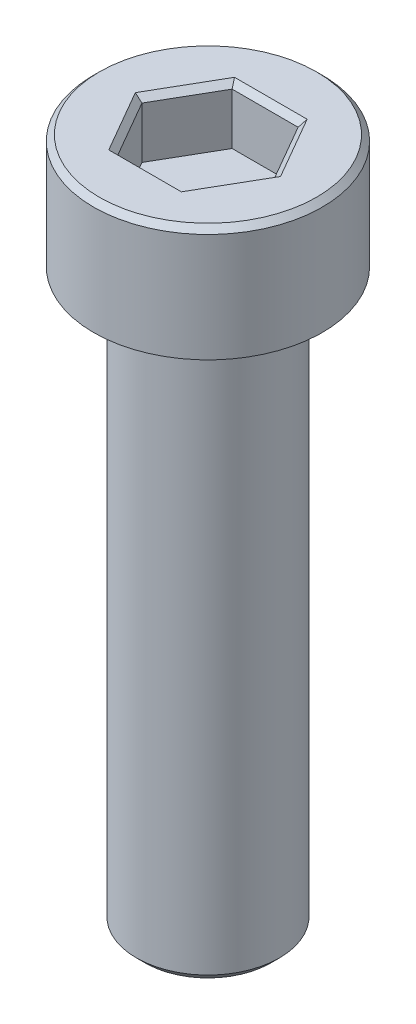
from build123d import *

# Parameters (mm, degrees)
SKETCH_1_R          = 4
EXTRUDE_1_DEPTH     = 4
SKETCH_2_R          = 2.5
EXTRUDE_2_DEPTH     = 20
CUT_EXTRUDE_1_DEPTH = 2
CHAMFER_1_SIZE      = 0.2
CHAMFER_2_SIZE      = 0.3


with BuildPart() as part:
    # 草图1 → 凸台-拉伸1 (new body)
    with BuildSketch(Plane(origin=(0, 0, 0), x_dir=(1, 0, 0), z_dir=(0, 1, 0))):
        Circle(SKETCH_1_R)
    extrude(amount=EXTRUDE_1_DEPTH)

    # 草图2 → 凸台-拉伸2 (add)
    with BuildSketch(Plane.XZ):
        Circle(SKETCH_2_R)
    extrude(amount=EXTRUDE_2_DEPTH)

    # 草图11 → 切除-拉伸1 (cut)
    with BuildSketch(Plane(origin=(0, 4, 0), x_dir=(1, 0, 0), z_dir=(0, 1, 0))):
        Polygon((1.154954177, 1.999853541), (-1.154446882, 2.000146427), (-2.309401058, 0.000292887), (-1.154954177, -1.999853541), (1.154446882, -2.000146427), (2.309401058, -0.000292887), align=None)
    extrude(amount=-CUT_EXTRUDE_1_DEPTH, mode=Mode.SUBTRACT)

    # 倒角1
    chamfer_1_edges = [part.edges().sort_by_distance(p)[0] for p in [
        (1.732177617, 4, -0.999780327),
        (0.000253647, 4, -1.999999984),
        (-1.73192397, 4, -1.000219657),
        (-1.732177617, 4, 0.999780327),
        (-0.000253647, 4, 1.999999984),
        (1.73192397, 4, 1.000219657),
        (-4, 4, 0),
    ]]
    chamfer(chamfer_1_edges, length=CHAMFER_1_SIZE)

    # 倒角2
    chamfer_2_edges = [part.edges().sort_by_distance(p)[0] for p in [
        (-2.5, -20, 0),
    ]]
    chamfer(chamfer_2_edges, length=CHAMFER_2_SIZE)


solid = part.part
